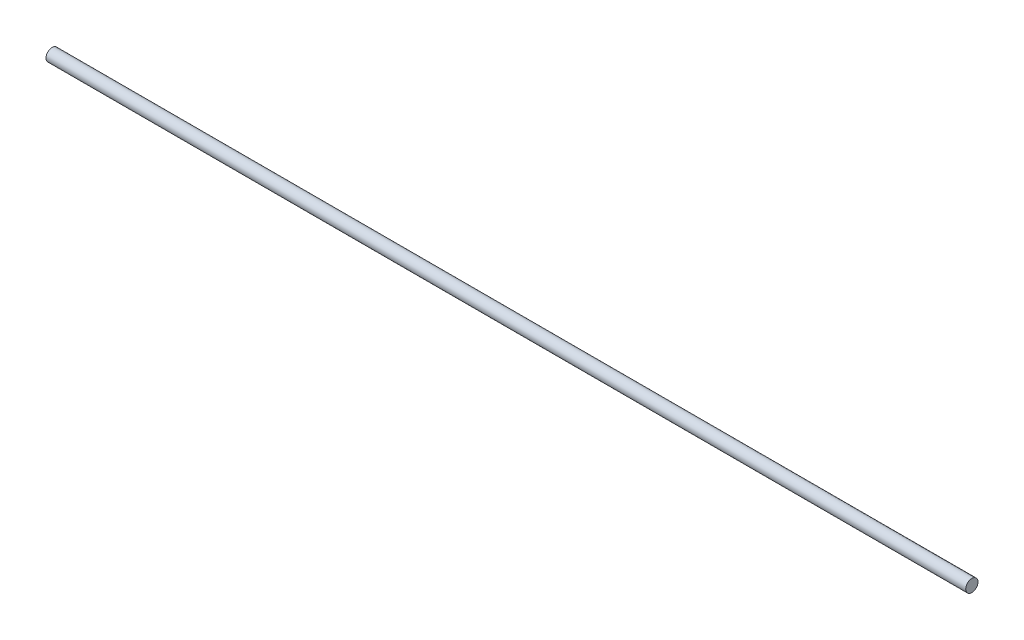
from build123d import *

# Parameters (mm, degrees)
BOSS_EXTRUDE1_DEPTH      = 300
BOSS_EXTRUDE1_DEPTH_BACK = 300
SKETCH1_R                = 4


with BuildPart() as part:
    # Sketch1 → Boss-Extrude1 (new, two sides: drawn at the far end of the back side and taken through both)
    with BuildSketch(Plane(origin=(0, 0, 0), x_dir=(0, 0, -1), z_dir=(1, 0, 0)).offset(-BOSS_EXTRUDE1_DEPTH_BACK)):
        Circle(SKETCH1_R)
    extrude(amount=BOSS_EXTRUDE1_DEPTH + BOSS_EXTRUDE1_DEPTH_BACK)


solid = part.part
